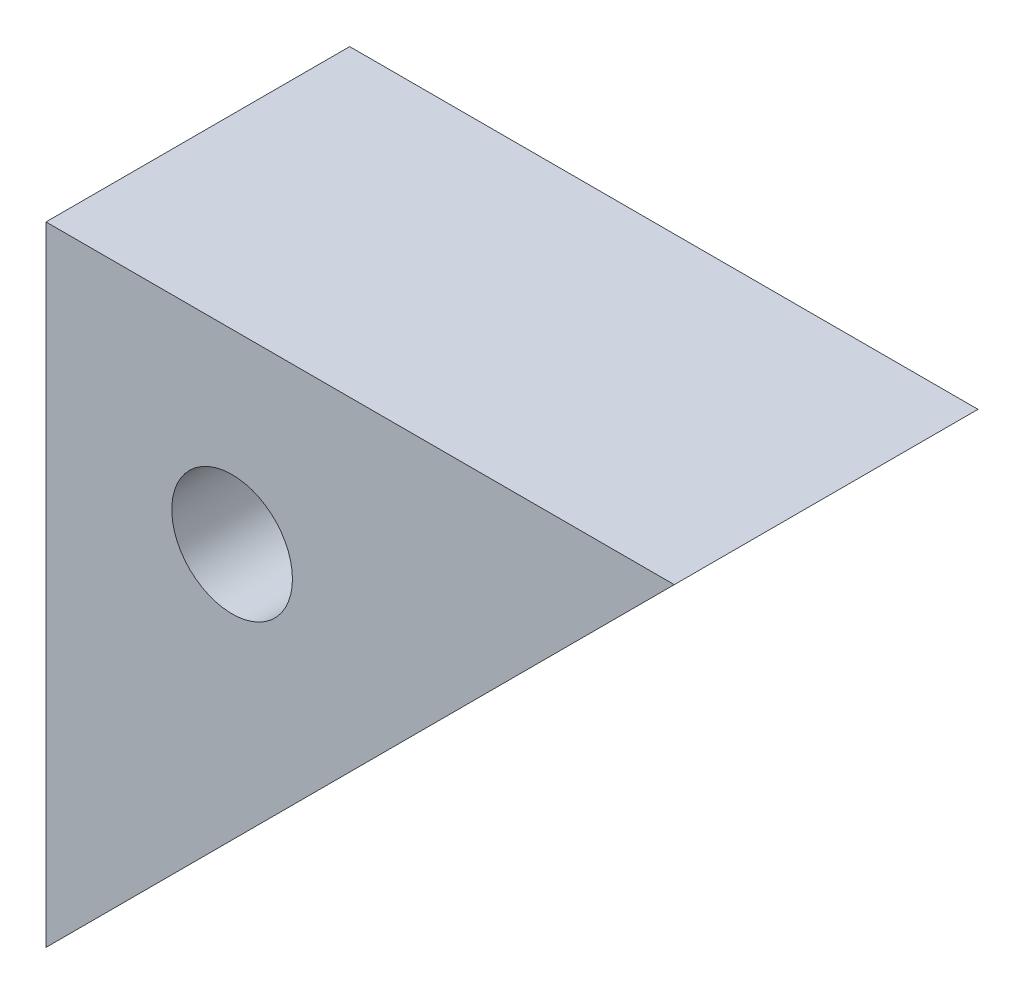
from build123d import *

# Parameters (mm, degrees)
BOSS_EXTRUDE1_DEPTH       = 5.8
F_6_32_TAPPED_HOLE4_D     = 2.305100038
F_6_32_TAPPED_HOLE4_DEPTH = 5.8


with BuildPart() as part:
    # Sketch1 → Boss-Extrude1 (new body)
    with BuildSketch(Plane.XY):
        Polygon((-33.2, 56.7), (-33.2, 44.7), (-21.2, 56.7), align=None)
    extrude(amount=-BOSS_EXTRUDE1_DEPTH)

    # #6-32 Tapped Hole4
    with Locations(Plane.XY):
        with Locations((-28.675364671, 25.000000038), (-29.645847618, 53.145847618)):
            Hole(F_6_32_TAPPED_HOLE4_D / 2, depth=F_6_32_TAPPED_HOLE4_DEPTH)


solid = part.part
